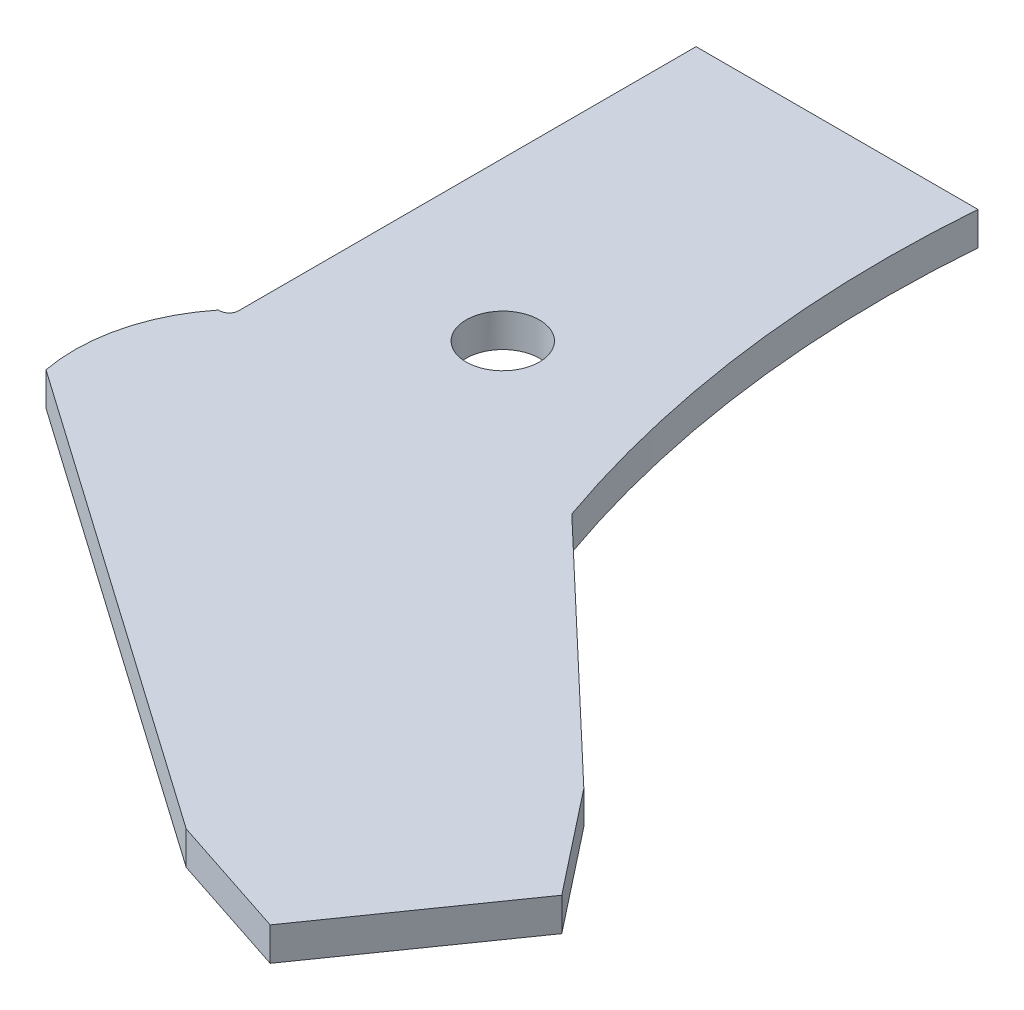
from build123d import *

# Parameters (mm, degrees)
SKETCH1_R           = 7.9375
BOSS_EXTRUDE1_DEPTH = 11.1125
SKETCH2_R           = 12.20390625
CUT_EXTRUDE1_DEPTH  = 11.1125


with BuildPart() as part:
    # Sketch1 → Boss-Extrude1 (new body)
    with BuildSketch(Plane(origin=(0, 0, 0), x_dir=(1, 0, 0), z_dir=(0, 1, 0))):
        with BuildLine():
            Line((47.0296875, 0), (-47.0296875, 0))
            Line((-47.0296875, 0), (-47.0296875, -152.5984375))
            ThreePointArc((-47.0296875, -152.5984375), (-47.95962347, -154.84350153), (-50.2046875, -155.7734375))
            Line((-50.2046875, -155.7734375), (-50.6015625, -155.7734375))
            ThreePointArc((-50.6015625, -155.7734375), (-61.399867308, -177.531283173), (-62.1109375, -201.8109375))
            Line((-62.1109375, -201.8109375), (93.937526937, -311.077248625))
            Line((93.937526937, -311.077248625), (135.682650242, -324.803661369))
            Line((135.682650242, -324.803661369), (175.746964321, -267.585891076))
            Line((175.746964321, -267.585891076), (148.570682499, -233.053016406))
            Line((148.570682499, -233.053016406), (67.2703125, -155.7734375))
            ThreePointArc((67.2703125, -155.7734375), (49.00058662, -78.945623418), (47.0296875, 0))
        make_face()
        with Locations((5.7546875, -117.2765625)):
            Circle(SKETCH1_R, mode=Mode.SUBTRACT)
    extrude(amount=BOSS_EXTRUDE1_DEPTH)

    # Sketch2 → Cut-Extrude1 (cut)
    with BuildSketch(Plane(origin=(0, 11.1125, 0), x_dir=(1, 0, 0), z_dir=(0, 1, 0))):
        with Locations((5.7546875, -117.2765625)):
            Circle(SKETCH2_R)
    extrude(amount=-CUT_EXTRUDE1_DEPTH, mode=Mode.SUBTRACT)


solid = part.part
